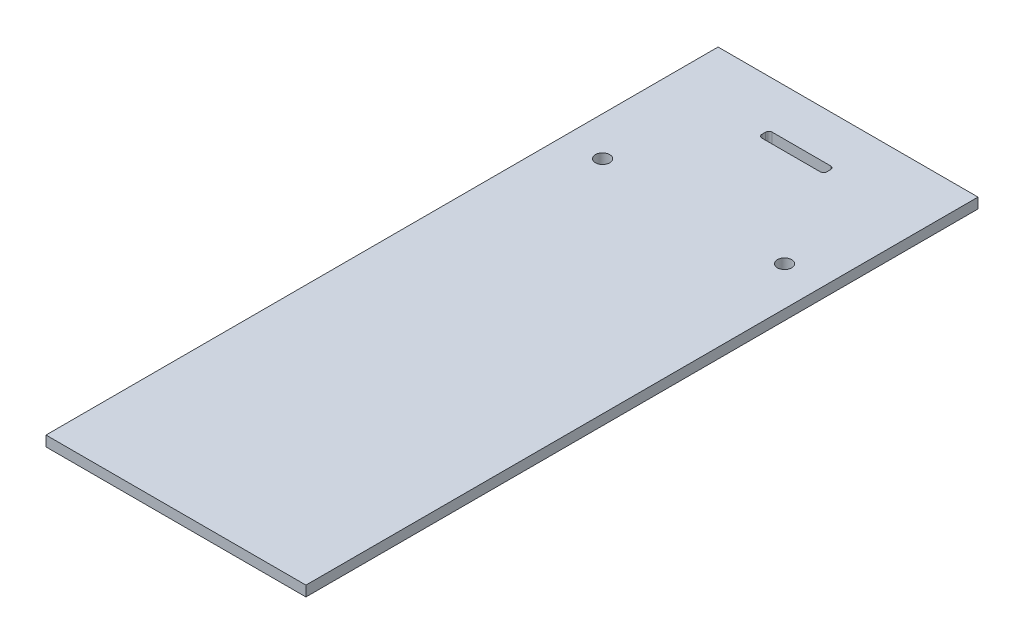
from build123d import *

# Parameters (mm, degrees)
SKETCH2_W           = 80
SKETCH2_H           = 206.85
BOSS_EXTRUDE1_DEPTH = 3.175
SKETCH3_R           = 2.2
SKETCH3_W           = 20
SKETCH3_H           = 3.175
CUT_EXTRUDE1_DEPTH  = 4.175
FILLET1_R           = 1


with BuildPart() as part:
    # Sketch2 → Boss-Extrude1 (new body)
    with BuildSketch(Plane(origin=(0, 0, 0), x_dir=(1, 0, 0), z_dir=(0, 1, 0))):
        Rectangle(SKETCH2_W, SKETCH2_H)
    extrude(amount=BOSS_EXTRUDE1_DEPTH)

    # Sketch3 → Cut-Extrude1 (cut, through all)
    with BuildSketch(Plane(origin=(0, 3.175, 0), x_dir=(1, 0, 0), z_dir=(0, 1, 0))):
        with Locations((28, 55.882836501)):
            Circle(SKETCH3_R)
        with Locations((-28, 55.882836501)):
            Circle(SKETCH3_R)
        with Locations((0, 87.470336501)):
            Rectangle(SKETCH3_W, SKETCH3_H)
    extrude(amount=-CUT_EXTRUDE1_DEPTH, mode=Mode.SUBTRACT)

    # Fillet1
    fillet1_edges = [part.edges().sort_by_distance(p)[0] for p in [
        (10, 1.5875, -89.057836501),
        (10, 1.5875, -85.882836501),
        (-10, 1.5875, -85.882836501),
        (-10, 1.5875, -89.057836501),
    ]]
    fillet(fillet1_edges, radius=FILLET1_R)


solid = part.part
